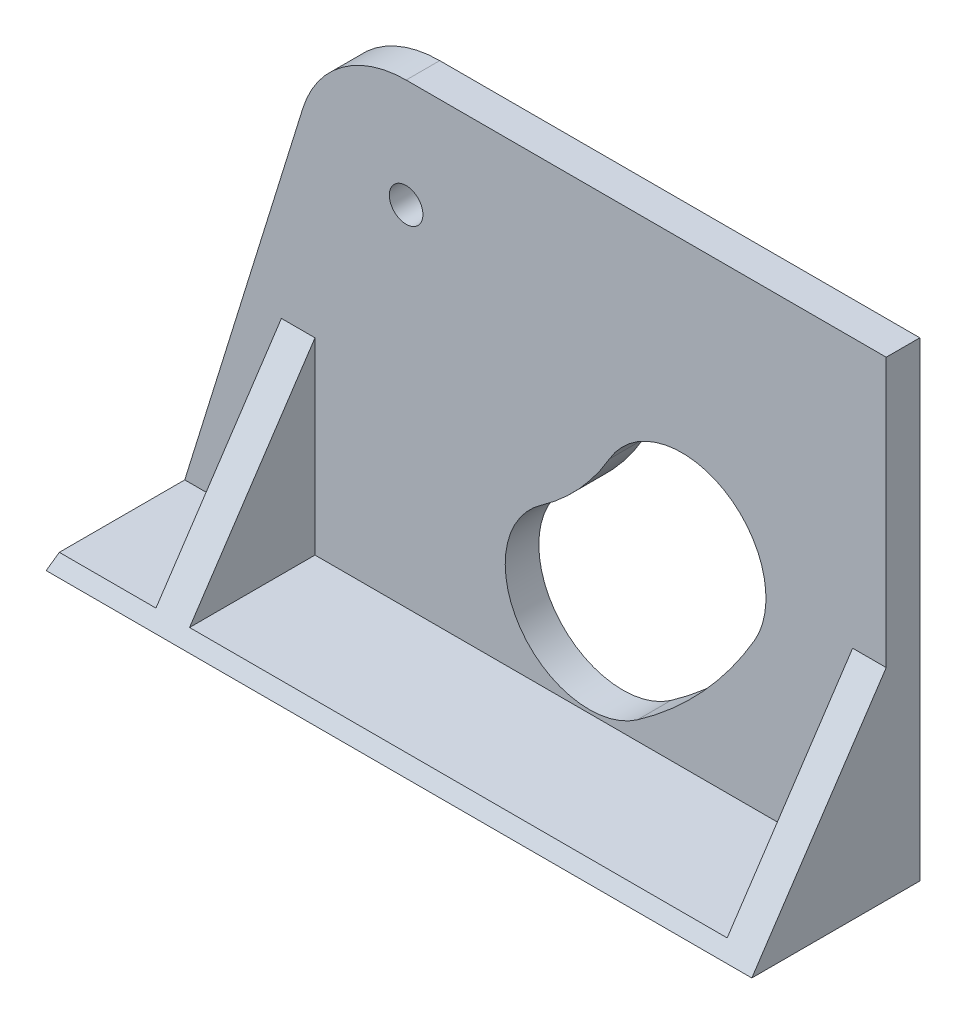
from build123d import *

# Parameters (mm, degrees)
SKETCH1_W           = 120
SKETCH1_H           = 100
BOSS_EXTRUDE1_DEPTH = 5
SKETCH2_R           = 2.5
CUT_EXTRUDE1_DEPTH  = 6
SKETCH3_W           = 120
SKETCH3_H           = 2
BOSS_EXTRUDE2_DEPTH = 20
CUT_EXTRUDE2_DEPTH  = 26
CUT_EXTRUDE3_DEPTH  = 26
SKETCH6_W           = 5
SKETCH6_H           = 30
BOSS_EXTRUDE3_DEPTH = 20
CUT_EXTRUDE4_DEPTH  = 106
SKETCH10_W          = 27.884556649
SKETCH10_H          = 70
CUT_EXTRUDE5_DEPTH  = 106


with BuildPart() as part:
    # Sketch1 → Boss-Extrude1 (new body)
    with BuildSketch(Plane.XY):
        with Locations((60, 50)):
            Rectangle(SKETCH1_W, SKETCH1_H)
    boss_extrude1 = extrude(amount=BOSS_EXTRUDE1_DEPTH)

    # Sketch2 → Cut-Extrude1 (cut, through all)
    with BuildSketch(Plane.XY.offset(5)):
        with Locations((48.561388608, 53.909722104)):
            Circle(SKETCH2_R)
        with BuildLine():
            ThreePointArc((82.975974789, 4.760599446), (92.719162031, 13.288409394), (100.405906554, 23.707967867))
            ThreePointArc((100.405906554, 23.707967867), (95.896997447, 40.800941239), (78.804024076, 36.292032133))
            ThreePointArc((78.804024076, 36.292032133), (74.320089771, 30.213956356), (68.63656388, 25.239400554))
            ThreePointArc((68.63656388, 25.239400554), (65.566868781, 7.830294546), (82.975974789, 4.760599446))
        make_face()
    cut_extrude1 = extrude(amount=-CUT_EXTRUDE1_DEPTH, mode=Mode.SUBTRACT)

    # Sketch3 → Boss-Extrude2 (add)
    with BuildSketch(Plane(origin=(0, 0, 0), x_dir=(-1, 0, 0), z_dir=(0, 0, -1))):
        with Locations((-60, 1)):
            Rectangle(SKETCH3_W, SKETCH3_H)
    boss_extrude2 = extrude(amount=BOSS_EXTRUDE2_DEPTH)

    # Sketch4 → Cut-Extrude2 (cut, through all)
    with BuildSketch(Plane.XY.offset(5)):
        with BuildLine():
            ThreePointArc((66.494283868, 35.596794606), (72.644903394, 39.60143936), (75.487572744, 46.368013909))
            ThreePointArc((75.487572744, 46.368013909), (73.248961533, 49.104548186), (70.512427256, 46.865936976))
            ThreePointArc((70.512427256, 46.865936976), (68.806825647, 42.805992246), (65.116453931, 40.403205394))
            ThreePointArc((65.116453931, 40.403205394), (63.402163505, 37.311085032), (66.494283868, 35.596794606))
        make_face()
    extrude(amount=-CUT_EXTRUDE2_DEPTH, mode=Mode.SUBTRACT)

    # Sketch5 → Cut-Extrude3 (cut, through all)
    with BuildSketch(Plane.XY.offset(5)):
        with BuildLine():
            Line((120, 70), (48.561388608, 70))
            ThreePointArc((48.561388608, 70), (39.016134462, 66.862913451), (33.192915272, 58.674915711))
            Line((33.192915272, 58.674915711), (15, 0))
            Line((15, 0), (0, 0))
            Line((0, 0), (0, 100))
            Line((0, 100), (120, 100))
            Line((120, 100), (120, 70))
        make_face()
    cut_extrude3 = extrude(amount=-CUT_EXTRUDE3_DEPTH, mode=Mode.SUBTRACT)

    # Sketch6 → Boss-Extrude3 (add, through all)
    with BuildSketch(Plane(origin=(0, 0, 0), x_dir=(-1, 0, 0), z_dir=(0, 0, -1))):
        with Locations((-117.5, 15)):
            Rectangle(SKETCH6_W, SKETCH6_H)
        with Locations((-32.5, 15)):
            Rectangle(SKETCH6_W, SKETCH6_H)
    boss_extrude3 = extrude(amount=BOSS_EXTRUDE3_DEPTH)

    # Sketch9 → Cut-Extrude4 (cut, through all)
    with BuildSketch(Plane(origin=(120, 0, 0), x_dir=(0, 0, -1), z_dir=(1, 0, 0))):
        Polygon((0, 30), (20, 0), (20, 30), align=None)
    cut_extrude4 = extrude(amount=-CUT_EXTRUDE4_DEPTH, mode=Mode.SUBTRACT)

    # Mirror1: Boss-Extrude1, Cut-Extrude1, Boss-Extrude2, Cut-Extrude3, Boss-Extrude3, Cut-Extrude4 across plane
    add(boss_extrude1.mirror(Plane(origin=(0, 0, 5), x_dir=(1, 0, 0), z_dir=(0, 0, -1))))
    add(cut_extrude1.mirror(Plane(origin=(0, 0, 5), x_dir=(1, 0, 0), z_dir=(0, 0, -1))), mode=Mode.SUBTRACT)
    add(boss_extrude2.mirror(Plane(origin=(0, 0, 5), x_dir=(1, 0, 0), z_dir=(0, 0, -1))))
    add(cut_extrude3.mirror(Plane(origin=(0, 0, 5), x_dir=(1, 0, 0), z_dir=(0, 0, -1))), mode=Mode.SUBTRACT)
    add(boss_extrude3.mirror(Plane(origin=(0, 0, 5), x_dir=(1, 0, 0), z_dir=(0, 0, -1))))
    add(cut_extrude4.mirror(Plane(origin=(0, 0, 5), x_dir=(1, 0, 0), z_dir=(0, 0, -1))), mode=Mode.SUBTRACT)

    # Sketch10 → Cut-Extrude5 (cut, through all)
    with BuildSketch(Plane(origin=(120, 0, 0), x_dir=(0, 0, -1), z_dir=(1, 0, 0))):
        with Locations((8.942278325, 35)):
            Rectangle(SKETCH10_W, SKETCH10_H)
    extrude(amount=-CUT_EXTRUDE5_DEPTH, mode=Mode.SUBTRACT)


solid = part.part
